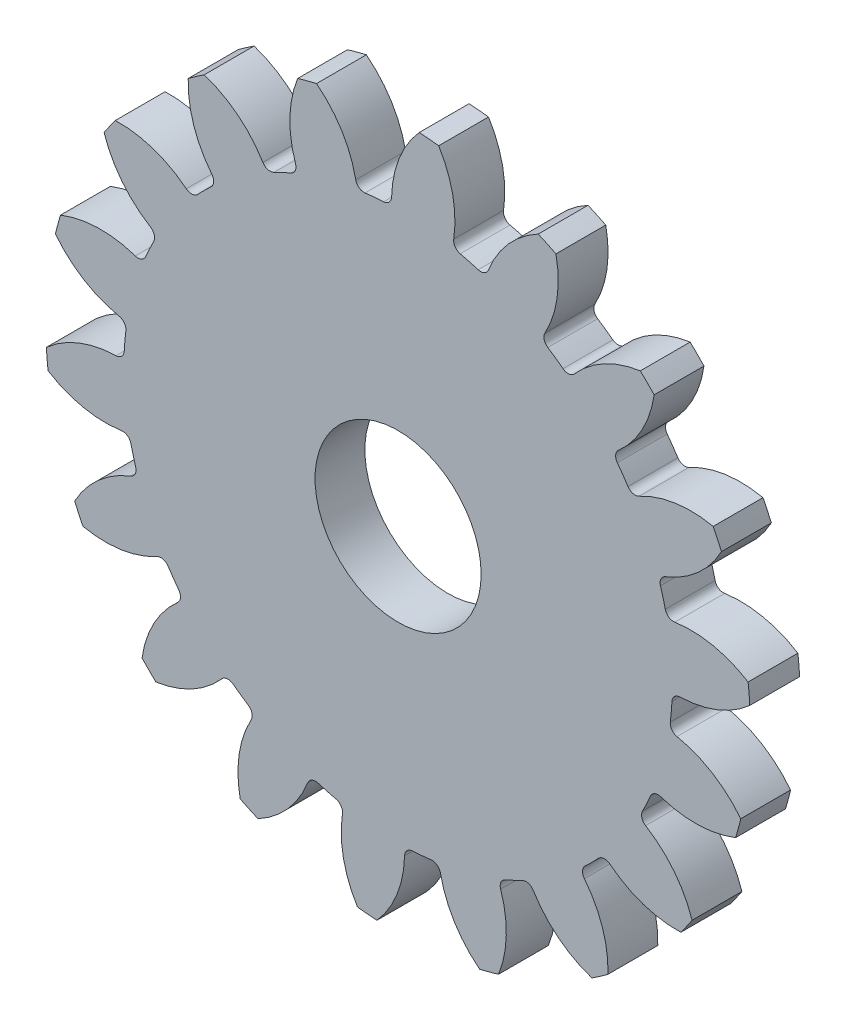
from build123d import *

# Parameters (mm, degrees)
CROQUIS1_R              = 21.209
SALIENTE_EXTRUIR1_DEPTH = 3
CORTAR_EXTRUIR1_DEPTH   = 4
REDONDEO1_R             = 0.508
MATRIZC1_COUNT          = 18
REDONDEO1_OF_MATRIZC1_R = 0.508
CROQUIS3_R              = 5
CORTAR_EXTRUIR2_DEPTH   = 4.0000001


with BuildPart() as part:
    # Croquis1 → Saliente-Extruir1 (new body)
    with BuildSketch(Plane.XY):
        Circle(CROQUIS1_R)
    extrude(amount=SALIENTE_EXTRUIR1_DEPTH)

    # Croquis2 → Cortar-Extruir1 (cut, through all)
    with BuildSketch(Plane.XY.offset(3)):
        with BuildLine():
            ThreePointArc((1.271245809, 21.170867131), (-1.838113333, 21.12919829), (-4.907958415, 20.633313481))
            ThreePointArc((-4.907958415, 20.633313481), (-3.264104792, 18.719203533), (-2.470715929, 16.324082296))
            ThreePointArc((-2.470715929, 16.324082296), (-1.430866667, 16.447878908), (-0.385260911, 16.505504356))
            ThreePointArc((-0.385260911, 16.505504356), (-0.017382785, 19.001648845), (1.271245809, 21.170867131))
        make_face()
    cortar_extruir1 = extrude(amount=-CORTAR_EXTRUIR1_DEPTH, mode=Mode.SUBTRACT)

    # Redondeo1
    redondeo1_edges = [part.edges().sort_by_distance(p)[0] for p in [
        (-0.385260911, 16.505504356, 1.5),
        (-2.470715929, 16.324082296, 1.5),
    ]]
    fillet(redondeo1_edges, radius=REDONDEO1_R)

    # MatrizC1: Cortar-Extruir1 ×18 about axis
    matrizc1_axis = Axis((0, 0, 0), (0, 0, 1))
    for i in range(1, MATRIZC1_COUNT):
        add(cortar_extruir1.rotate(matrizc1_axis, i * 360 / MATRIZC1_COUNT), mode=Mode.SUBTRACT)

    # Redondeo1 of MatrizC1
    redondeo1_of_matrizc1_edges = [part.edges().sort_by_distance(p)[0] for p in [
        (-6.0072418, 15.378333653, 1.5),
        (-7.904878493, 14.494585058, 1.5),
        (-10.904660671, 12.396308953, 1.5),
        (-12.385596047, 10.916826946, 1.5),
        (-14.48681653, 7.919106442, 1.5),
        (-15.372427926, 6.022338388, 1.5),
        (-16.321648512, 2.486742821, 1.5),
        (-16.505118124, 0.401466941, 1.5),
        (-16.187848802, -3.245558685, 1.5),
        (-15.647047487, -5.267827345, 1.5),
        (-14.101555619, -8.586397914, 1.5),
        (-12.901711997, -10.301743908, 1.5),
        (-10.314406712, -12.891590832, 1.5),
        (-8.600239632, -14.093118118, 1.5),
        (-5.28318813, -15.641867637, 1.5),
        (-3.26145144, -16.184654291, 1.5),
        (0.385260911, -16.505504356, 1.5),
        (2.470715929, -16.324082296, 1.5),
        (6.0072418, -15.378333653, 1.5),
        (7.904878493, -14.494585058, 1.5),
        (10.904660671, -12.396308953, 1.5),
        (12.385596047, -10.916826946, 1.5),
        (14.48681653, -7.919106442, 1.5),
        (15.372427926, -6.022338388, 1.5),
        (16.321648512, -2.486742821, 1.5),
        (16.505118124, -0.401466941, 1.5),
        (16.187848802, 3.245558685, 1.5),
        (15.647047487, 5.267827345, 1.5),
        (14.101555619, 8.586397914, 1.5),
        (12.901711997, 10.301743908, 1.5),
        (10.314406712, 12.891590832, 1.5),
        (8.600239632, 14.093118118, 1.5),
        (5.28318813, 15.641867637, 1.5),
        (3.26145144, 16.184654291, 1.5),
    ]]
    fillet(redondeo1_of_matrizc1_edges, radius=REDONDEO1_OF_MATRIZC1_R)

    # Croquis3 → Cortar-Extruir2 (cut, through all)
    with BuildSketch(Plane.XY.offset(3)):
        Circle(CROQUIS3_R)
    extrude(amount=-CORTAR_EXTRUIR2_DEPTH, mode=Mode.SUBTRACT)


solid = part.part
